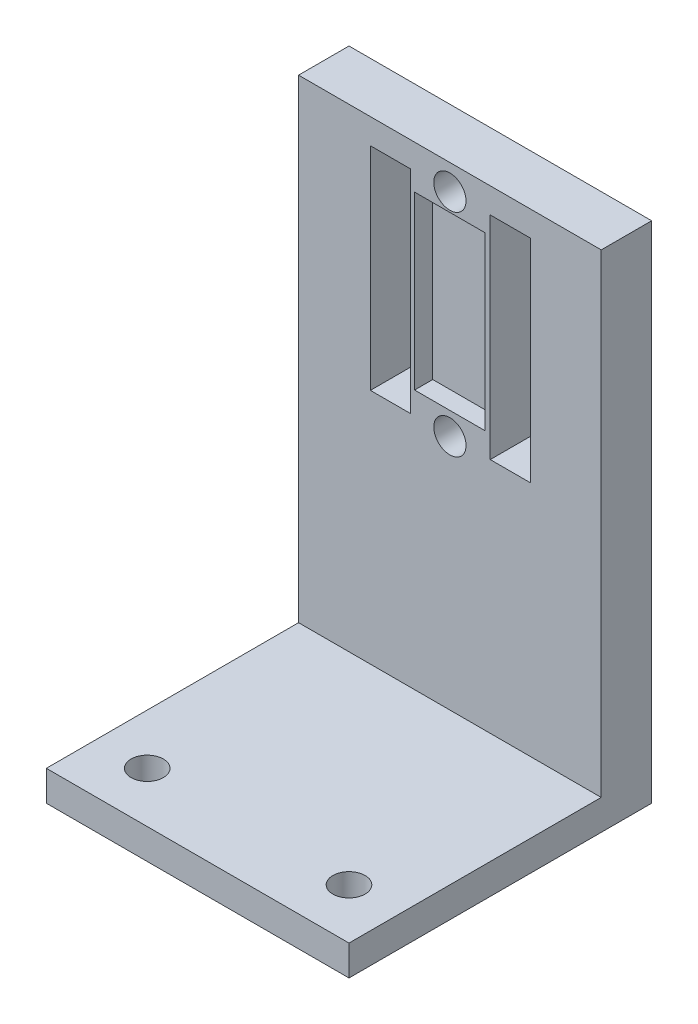
from build123d import *

# Parameters (mm, degrees)
SKETCH_1_R          = 1.6
EXTRUDE_1_DEPTH     = 3
EXTRUDE_2_DEPTH     = 50
SKETCH_2_R          = 1.6
SKETCH_2_W          = 4
SKETCH_2_H          = 21
CUT_EXTRUDE_1_DEPTH = 58.879184514
SKETCH_3_W          = 7
SKETCH_3_H          = 16.993149035
CUT_EXTRUDE_5_DEPTH = 1.8


with BuildPart() as part:
    # 草图1 → 凸台-拉伸1 (new body)
    with BuildSketch(Plane(origin=(0, 0, 0), x_dir=(1, 0, 0), z_dir=(0, 1, 0))):
        Polygon((-10, 0), (0, 0), (10, 0), (15, 0), (15, 25), (10, 25), (-15, 25), (-15, 0), align=None)
        with Locations((-10, 5)):
            Circle(SKETCH_1_R, mode=Mode.SUBTRACT)
        with BuildLine():
            ThreePointArc((11.6, 5), (8.86862915, 3.86862915), (10, 6.6))
            ThreePointArc((10, 6.6), (11.13137085, 6.13137085), (11.6, 5))
        make_face(mode=Mode.SUBTRACT)
    extrude(amount=EXTRUDE_1_DEPTH)

    # 草图1<3> → 凸台-拉伸2 (add)
    with BuildSketch(Plane(origin=(0, 0, 0), x_dir=(1, 0, 0), z_dir=(0, 1, 0))):
        Polygon((10, 25), (15, 25), (15, 30), (-15, 30), (-15, 25), align=None)
    extrude(amount=EXTRUDE_2_DEPTH)

    # 草图2 → 切除-拉伸1 (cut, through all)
    with BuildSketch(Plane.XY.offset(-25)):
        with Locations((0, 47.5)):
            Circle(SKETCH_2_R)
        with Locations((0, 26.5)):
            Circle(SKETCH_2_R)
        with Locations((6, 37)):
            Rectangle(SKETCH_2_W, SKETCH_2_H)
        with Locations((-5.879917392, 37)):
            Rectangle(SKETCH_2_W, SKETCH_2_H)
    extrude(amount=-CUT_EXTRUDE_1_DEPTH, mode=Mode.SUBTRACT)

    # 草图3 → 切除-拉伸5 (cut)
    with BuildSketch(Plane.XY.offset(-25)):
        with Locations((0, 37.216442025)):
            Rectangle(SKETCH_3_W, SKETCH_3_H)
    extrude(amount=-CUT_EXTRUDE_5_DEPTH, mode=Mode.SUBTRACT)


solid = part.part
